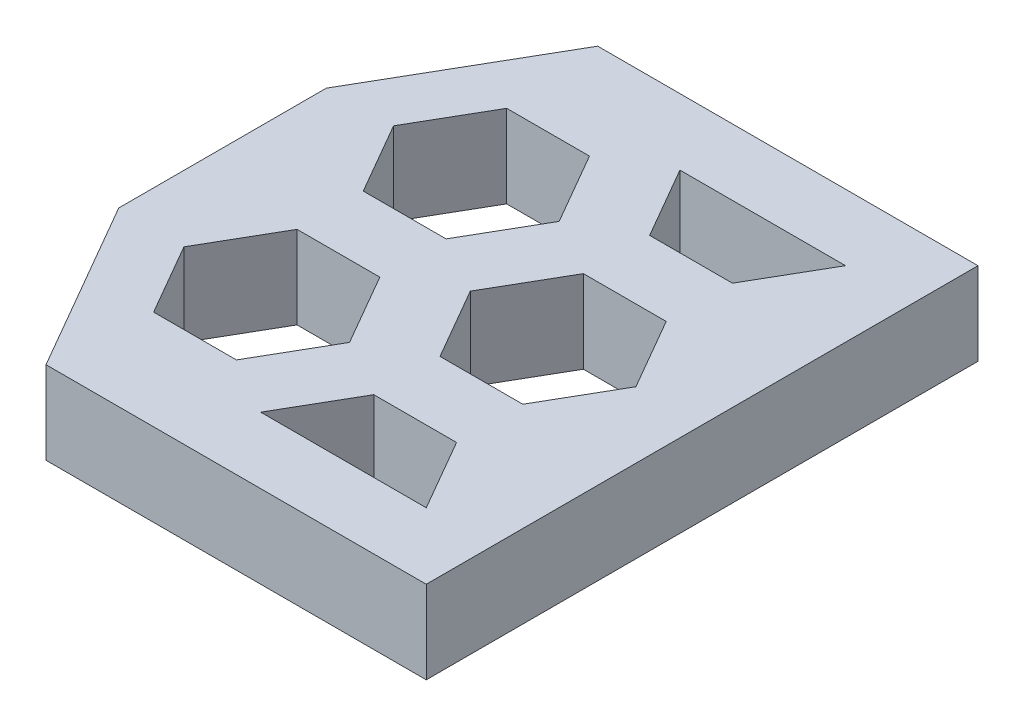
from build123d import *

# Parameters (mm, degrees)
SKETCH1_W             = 14.482050808
SKETCH1_H             = 16.660254038
BOSS_EXTRUDE1_DEPTH   = 2.5
CHAMFER1_SIZE         = 3
CHAMFER1_SIZE2        = 5.196152423
CHAMFER1_PART_2_SIZE  = 3
CHAMFER1_PART_2_SIZE2 = 5.196152423


with BuildPart() as part:
    # Sketch1 → Boss-Extrude1 (new body)
    with BuildSketch(Plane(origin=(0, 0, 0), x_dir=(1, 0, 0), z_dir=(0, 1, 0))):
        with Locations((7.241025404, 8.330127019)):
            Rectangle(SKETCH1_W, SKETCH1_H)
        Polygon((7.482050808, 14.660254038), (12.482050808, 14.660254038), (11.232050808, 12.495190528), (8.732050808, 12.495190528), align=None, mode=Mode.SUBTRACT)
        Polygon((7, 11.495190528), (5.75, 13.660254038), (3.25, 13.660254038), (2, 11.495190528), (3.25, 9.330127019), (5.75, 9.330127019), align=None, mode=Mode.SUBTRACT)
        Polygon((7, 5.165063509), (5.75, 7.330127019), (3.25, 7.330127019), (2, 5.165063509), (3.25, 3), (5.75, 3), align=None, mode=Mode.SUBTRACT)
        Polygon((12.482050808, 8.330127019), (11.232050808, 10.495190528), (8.732050808, 10.495190528), (7.482050808, 8.330127019), (8.732050808, 6.165063509), (11.232050808, 6.165063509), align=None, mode=Mode.SUBTRACT)
        Polygon((7.482050808, 2), (12.482050808, 2), (11.232050808, 4.165063509), (8.732050808, 4.165063509), align=None, mode=Mode.SUBTRACT)
    extrude(amount=BOSS_EXTRUDE1_DEPTH)

    # Chamfer1
    chamfer1_edges = [part.edges().sort_by_distance(p)[0] for p in [
        (0, 1.25, -16.660254038),
    ]]
    chamfer1_side = [part.faces().sort_by_distance(p)[0] for p in [
        (7.241025404, 1.25, -16.660254038),
    ]]
    chamfer(chamfer1_edges, length=CHAMFER1_SIZE, length2=CHAMFER1_SIZE2, reference=chamfer1_side[0])

    # Chamfer1 part 2
    chamfer1_part_2_edges = [part.edges().sort_by_distance(p)[0] for p in [
        (0, 1.25, 0),
    ]]
    chamfer1_part_2_side = [part.faces().sort_by_distance(p)[0] for p in [
        (7.241025404, 1.25, 0),
    ]]
    chamfer(chamfer1_part_2_edges, length=CHAMFER1_PART_2_SIZE, length2=CHAMFER1_PART_2_SIZE2, reference=chamfer1_part_2_side[0])


solid = part.part
